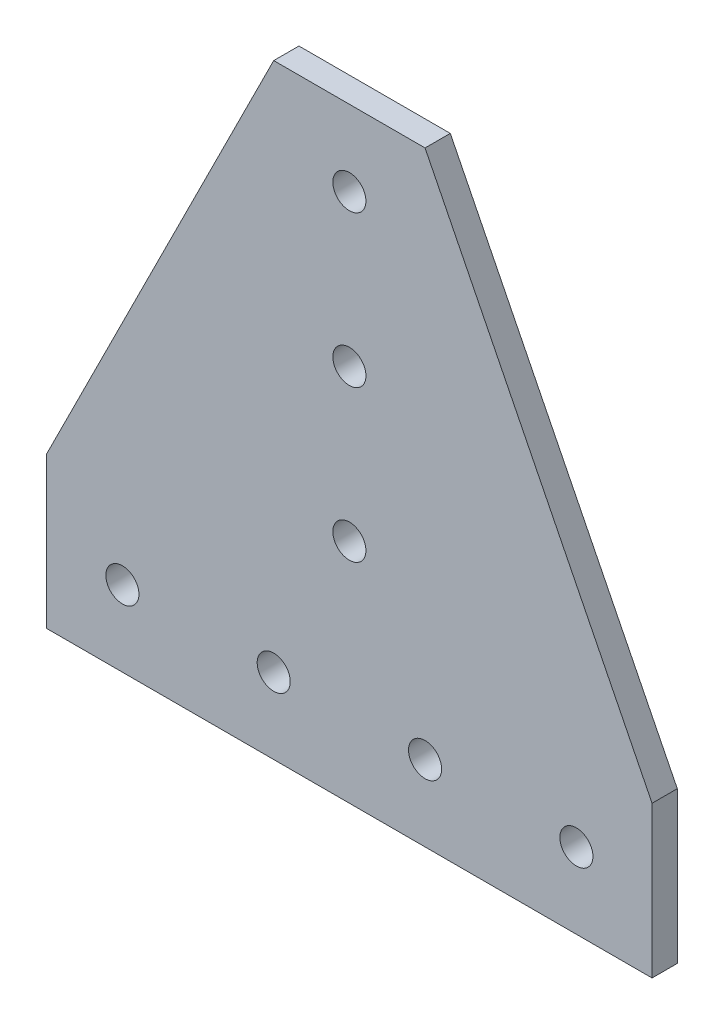
from build123d import *

# Parameters (mm, degrees)
SKETCH1_R           = 4.1656
BOSS_EXTRUDE1_DEPTH = 6.35


with BuildPart() as part:
    # Sketch1 → Boss-Extrude1 (new body)
    with BuildSketch(Plane.XY.offset(6.35)):
        Polygon((-19.05, 152.4), (-76.2, 38.1), (-76.2, 0), (76.2, 0), (76.2, 38.1), (19.05, 152.4), align=None)
        with Locations((-57.15, 19.05)):
            Circle(SKETCH1_R, mode=Mode.SUBTRACT)
        with Locations((-19.05, 19.05)):
            Circle(SKETCH1_R, mode=Mode.SUBTRACT)
        with Locations((0, 133.35)):
            Circle(SKETCH1_R, mode=Mode.SUBTRACT)
        with Locations((0, 95.25)):
            Circle(SKETCH1_R, mode=Mode.SUBTRACT)
        with Locations((0, 57.15)):
            Circle(SKETCH1_R, mode=Mode.SUBTRACT)
        with Locations((19.05, 19.05)):
            Circle(SKETCH1_R, mode=Mode.SUBTRACT)
        with Locations((57.15, 19.05)):
            Circle(SKETCH1_R, mode=Mode.SUBTRACT)
    extrude(amount=-BOSS_EXTRUDE1_DEPTH)


solid = part.part
